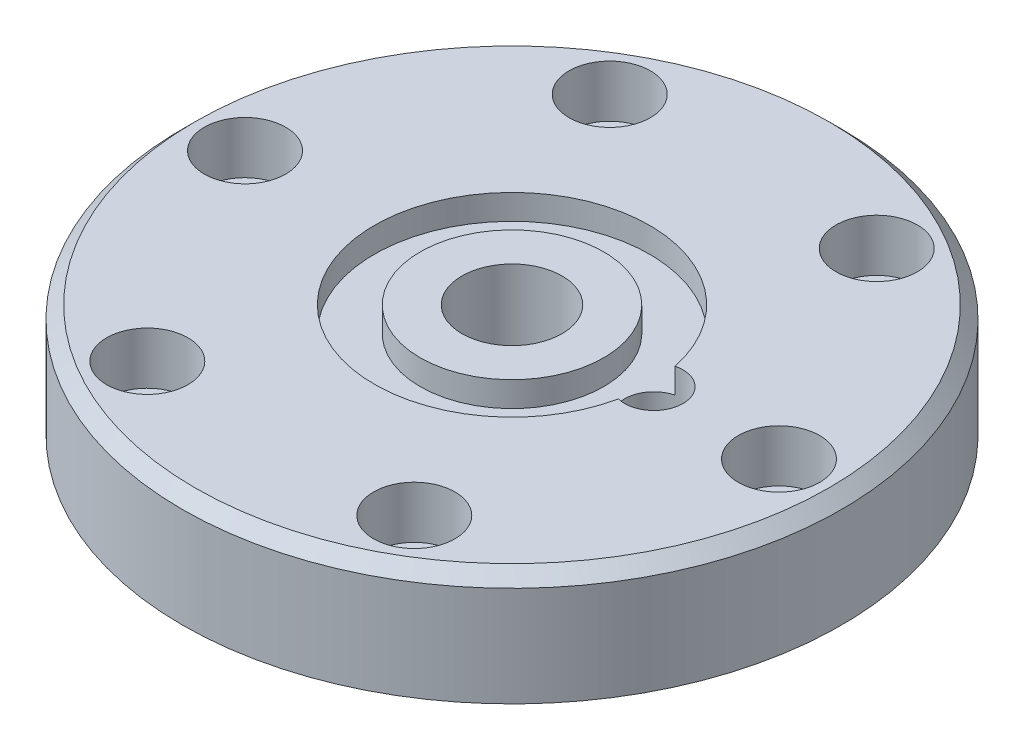
from build123d import *

# Parameters (mm, degrees)
SKETCH1_R                                           = 79
SKETCH1_R_2                                         = 12
BOSS_EXTRUDE3_DEPTH                                 = 27
CBORE_FOR_00_BINDING_HEAD_MACHINE_SCREW_D           = 12.499999892
CBORE_FOR_00_BINDING_HEAD_MACHINE_SCREW_CBORE_D     = 19.500000116
CBORE_FOR_00_BINDING_HEAD_MACHINE_SCREW_CBORE_DEPTH = 12.499999892
F_97_0_0059_DIAMETER_HOLE1_D                        = 13.99999994
F_97_0_0059_DIAMETER_HOLE1_DEPTH                    = 17
F_97_0_0059_DIAMETER_HOLE1_TIP                      = 4.206024315
SKETCH8_R                                           = 33
SKETCH8_R_2                                         = 22
CUT_EXTRUDE1_DEPTH                                  = 6
CHAMFER1_SIZE                                       = 3


with BuildPart() as part:
    # Sketch1 → Boss-Extrude3 (new body)
    with BuildSketch(Plane(origin=(0, 0, 0), x_dir=(1, 0, 0), z_dir=(0, 1, 0))):
        Circle(SKETCH1_R)
        Circle(SKETCH1_R_2, mode=Mode.SUBTRACT)
    extrude(amount=BOSS_EXTRUDE3_DEPTH)

    # CBORE for #00 Binding Head Machine Screw1 (through all)
    with Locations(Plane(origin=(0, 27, 0), x_dir=(1, 0, 0), z_dir=(0, 1, 0))):
        with Locations((32, 55.425625842), (64, 0), (32, -55.425625842), (-32, -55.425625842), (-64, 0), (-32, 55.425625842), (0, 0)):
            CounterBoreHole(CBORE_FOR_00_BINDING_HEAD_MACHINE_SCREW_D / 2, CBORE_FOR_00_BINDING_HEAD_MACHINE_SCREW_CBORE_D / 2, CBORE_FOR_00_BINDING_HEAD_MACHINE_SCREW_CBORE_DEPTH)

    # #97 (0.0059) Diameter Hole1
    with Locations(Plane(origin=(0, 27, 0), x_dir=(1, 0, 0), z_dir=(0, 1, 0))):
        with Locations((34, 0)):
            Hole(F_97_0_0059_DIAMETER_HOLE1_D / 2, depth=F_97_0_0059_DIAMETER_HOLE1_DEPTH)
            with Locations((0, 0, -(F_97_0_0059_DIAMETER_HOLE1_DEPTH + F_97_0_0059_DIAMETER_HOLE1_TIP / 2))):  # 118° drill point
                Cone(0, F_97_0_0059_DIAMETER_HOLE1_D / 2, F_97_0_0059_DIAMETER_HOLE1_TIP, mode=Mode.SUBTRACT)

    # Sketch8 → Cut-Extrude1 (cut)
    with BuildSketch(Plane(origin=(0, 27, 0), x_dir=(1, 0, 0), z_dir=(0, 1, 0))):
        Circle(SKETCH8_R)
        Circle(SKETCH8_R_2, mode=Mode.SUBTRACT)
    extrude(amount=-CUT_EXTRUDE1_DEPTH, mode=Mode.SUBTRACT)

    # Chamfer1
    chamfer1_edges = [part.edges().sort_by_distance(p)[0] for p in [
        (-79, 27, 0),
    ]]
    chamfer(chamfer1_edges, length=CHAMFER1_SIZE)


solid = part.part
